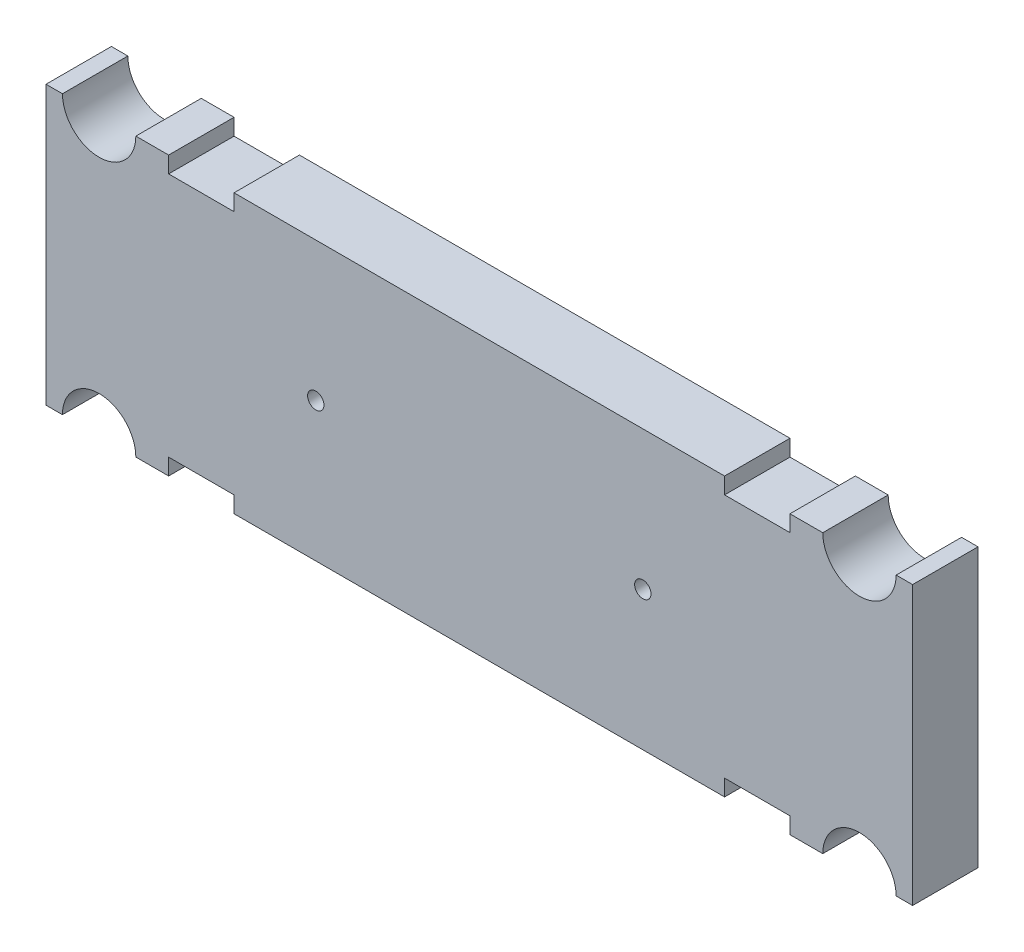
from build123d import *

# Parameters (mm, degrees)
AUFSATZ_LINEAR_AUSTRAGEN1_DEPTH = 4
SCHNITT_LINEAR_AUSTRAGEN1_REACH = 6
SKIZZE2_R                       = 0.5


with BuildPart() as part:
    # Skizze1 → Aufsatz-Linear austragen1 (new body)
    with BuildSketch(Plane.XY):
        with BuildLine():
            Line((26.5, 8.5), (25.493621062, 8.5))
            ThreePointArc((25.493621062, 8.5), (23.25, 6.256378938), (21.006378938, 8.5))
            Line((21.006378938, 8.5), (19, 8.5))
            Line((19, 8.5), (19, 7.5))
            Line((19, 7.5), (15, 7.5))
            Line((15, 7.5), (15, 8.5))
            Line((15, 8.5), (-15, 8.5))
            Line((-15, 8.5), (-15, 7.5))
            Line((-15, 7.5), (-19, 7.5))
            Line((-19, 7.5), (-19, 8.5))
            Line((-19, 8.5), (-21.006378938, 8.5))
            ThreePointArc((-21.006378938, 8.5), (-23.25, 6.256378938), (-25.493621062, 8.5))
            Line((-25.493621062, 8.5), (-26.5, 8.5))
            Line((-26.5, 8.5), (-26.5, -8.5))
            Line((-26.5, -8.5), (-25.493621062, -8.5))
            ThreePointArc((-25.493621062, -8.5), (-23.25, -6.256378938), (-21.006378938, -8.5))
            Line((-21.006378938, -8.5), (-19, -8.5))
            Line((-19, -8.5), (-19, -7.5))
            Line((-19, -7.5), (-15, -7.5))
            Line((-15, -7.5), (-15, -8.5))
            Line((-15, -8.5), (15, -8.5))
            Line((15, -8.5), (15, -7.5))
            Line((15, -7.5), (19, -7.5))
            Line((19, -7.5), (19, -8.5))
            Line((19, -8.5), (21.006378938, -8.5))
            ThreePointArc((21.006378938, -8.5), (23.25, -6.256378938), (25.493621062, -8.5))
            Line((25.493621062, -8.5), (26.5, -8.5))
            Line((26.5, -8.5), (26.5, 8.5))
        make_face()
    extrude(amount=AUFSATZ_LINEAR_AUSTRAGEN1_DEPTH)

    # Skizze2 → Schnitt-Linear austragen1 (cut, up to next)
    with BuildSketch(Plane.XY.offset(4), mode=Mode.PRIVATE) as schnitt_linear_austragen1_sk1:
        with Locations((-10, 0)):
            Circle(SKIZZE2_R)
    schnitt_linear_austragen1_tool1 = extrude(schnitt_linear_austragen1_sk1.sketch, amount=-SCHNITT_LINEAR_AUSTRAGEN1_REACH, mode=Mode.PRIVATE) & part.part
    add(schnitt_linear_austragen1_tool1.solids().sort_by_distance((-10, 0, 4))[0], mode=Mode.SUBTRACT)
    # Skizze2 → Schnitt-Linear austragen1 (cut, up to next)
    with BuildSketch(Plane.XY.offset(4), mode=Mode.PRIVATE) as schnitt_linear_austragen1_sk2:
        with Locations((10, 0)):
            Circle(SKIZZE2_R)
    schnitt_linear_austragen1_tool2 = extrude(schnitt_linear_austragen1_sk2.sketch, amount=-SCHNITT_LINEAR_AUSTRAGEN1_REACH, mode=Mode.PRIVATE) & part.part
    add(schnitt_linear_austragen1_tool2.solids().sort_by_distance((10, 0, 4))[0], mode=Mode.SUBTRACT)


solid = part.part
